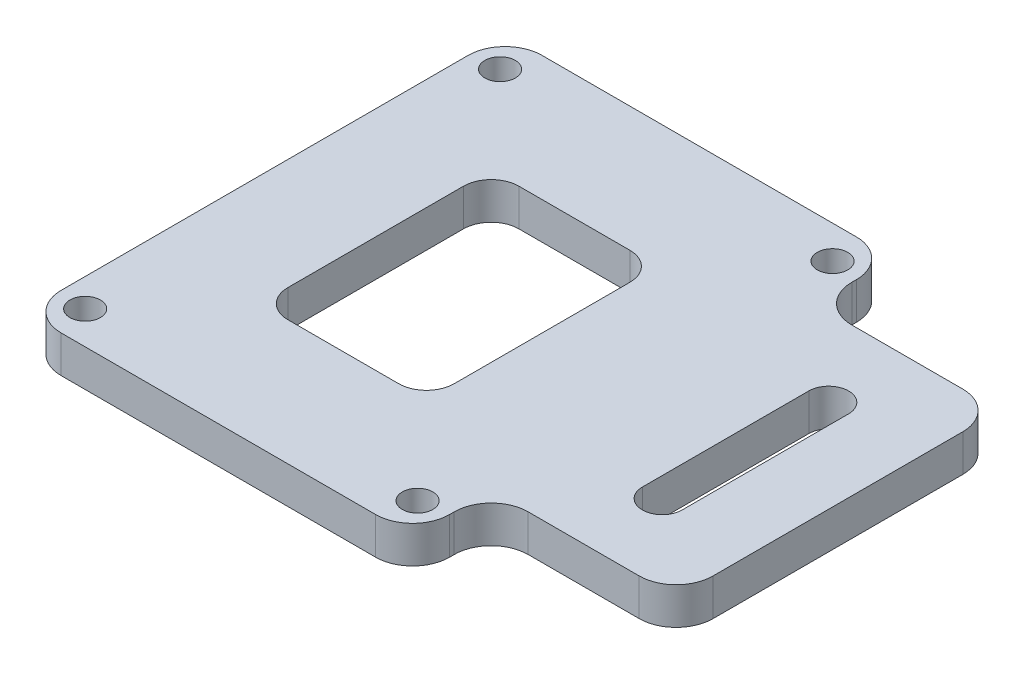
from build123d import *

# Parameters (mm, degrees)
SKETCH1_W               = 42
SKETCH1_H               = 52
BOSS_EXTRUDE1_DEPTH     = 4
SKETCH2_R               = 1.65
CUT_EXTRUDE1_DEPTH      = 1
CUT_EXTRUDE1_DEPTH_BACK = 5
SKETCH3_W               = 20
SKETCH3_H               = 35
BOSS_EXTRUDE2_DEPTH     = 4
FILLET1_R               = 4
CUT_EXTRUDE2_DEPTH      = 1
CUT_EXTRUDE2_DEPTH_BACK = 5
SKETCH5_W               = 18
SKETCH5_H               = 25
CUT_EXTRUDE3_DEPTH      = 1
CUT_EXTRUDE3_DEPTH_BACK = 5
FILLET2_R               = 3


with BuildPart() as part:
    # Sketch1 → Boss-Extrude1 (new body)
    with BuildSketch(Plane(origin=(0, 0, 0), x_dir=(1, 0, 0), z_dir=(0, 1, 0))):
        Rectangle(SKETCH1_W, SKETCH1_H)
    extrude(amount=BOSS_EXTRUDE1_DEPTH)

    # Sketch2 → Cut-Extrude1 (cut, two sides)
    with BuildSketch(Plane(origin=(0, 4, 0), x_dir=(1, 0, 0), z_dir=(0, 1, 0))) as cut_extrude1_sk:
        with Locations((-17.975, 22.4375)):
            Circle(SKETCH2_R)
        with Locations((17.975, 22.4375)):
            Circle(SKETCH2_R)
        with Locations((17.975, -22.4375)):
            Circle(SKETCH2_R)
        with Locations((-17.975, -22.4375)):
            Circle(SKETCH2_R)
    extrude(amount=CUT_EXTRUDE1_DEPTH, mode=Mode.SUBTRACT)
    extrude(cut_extrude1_sk.sketch, amount=-CUT_EXTRUDE1_DEPTH_BACK, mode=Mode.SUBTRACT)

    # Sketch3 → Boss-Extrude2 (add)
    with BuildSketch(Plane(origin=(0, 4, 0), x_dir=(1, 0, 0), z_dir=(0, 1, 0))):
        with Locations((31, 0)):
            Rectangle(SKETCH3_W, SKETCH3_H)
    extrude(amount=-BOSS_EXTRUDE2_DEPTH)

    # Fillet1
    fillet1_edges = [part.edges().sort_by_distance(p)[0] for p in [
        (21, 2, 17.5),
        (21, 2, -17.5),
        (41, 2, -17.5),
        (41, 2, 17.5),
        (21, 2, 26),
        (-21, 2, 26),
        (-21, 2, -26),
        (21, 2, -26),
    ]]
    fillet(fillet1_edges, radius=FILLET1_R)

    # Sketch4 → Cut-Extrude2 (cut, two sides)
    with BuildSketch(Plane(origin=(0, 4, 0), x_dir=(1, 0, 0), z_dir=(0, 1, 0))) as cut_extrude2_sk:
        with BuildLine():
            Line((28.85, -9), (28.85, 9))
            ThreePointArc((28.85, 9), (31, 11.15), (33.15, 9))
            Line((33.15, 9), (33.15, -9))
            ThreePointArc((33.15, -9), (31, -11.15), (28.85, -9))
        make_face()
    extrude(amount=CUT_EXTRUDE2_DEPTH, mode=Mode.SUBTRACT)
    extrude(cut_extrude2_sk.sketch, amount=-CUT_EXTRUDE2_DEPTH_BACK, mode=Mode.SUBTRACT)

    # Sketch5 → Cut-Extrude3 (cut, two sides)
    with BuildSketch(Plane(origin=(0, 4, 0), x_dir=(1, 0, 0), z_dir=(0, 1, 0))) as cut_extrude3_sk:
        Rectangle(SKETCH5_W, SKETCH5_H)
    extrude(amount=CUT_EXTRUDE3_DEPTH, mode=Mode.SUBTRACT)
    extrude(cut_extrude3_sk.sketch, amount=-CUT_EXTRUDE3_DEPTH_BACK, mode=Mode.SUBTRACT)

    # Fillet2
    fillet2_edges = [part.edges().sort_by_distance(p)[0] for p in [
        (9, 2, -12.5),
        (9, 2, 12.5),
        (-9, 2, 12.5),
        (-9, 2, -12.5),
    ]]
    fillet(fillet2_edges, radius=FILLET2_R)


solid = part.part
